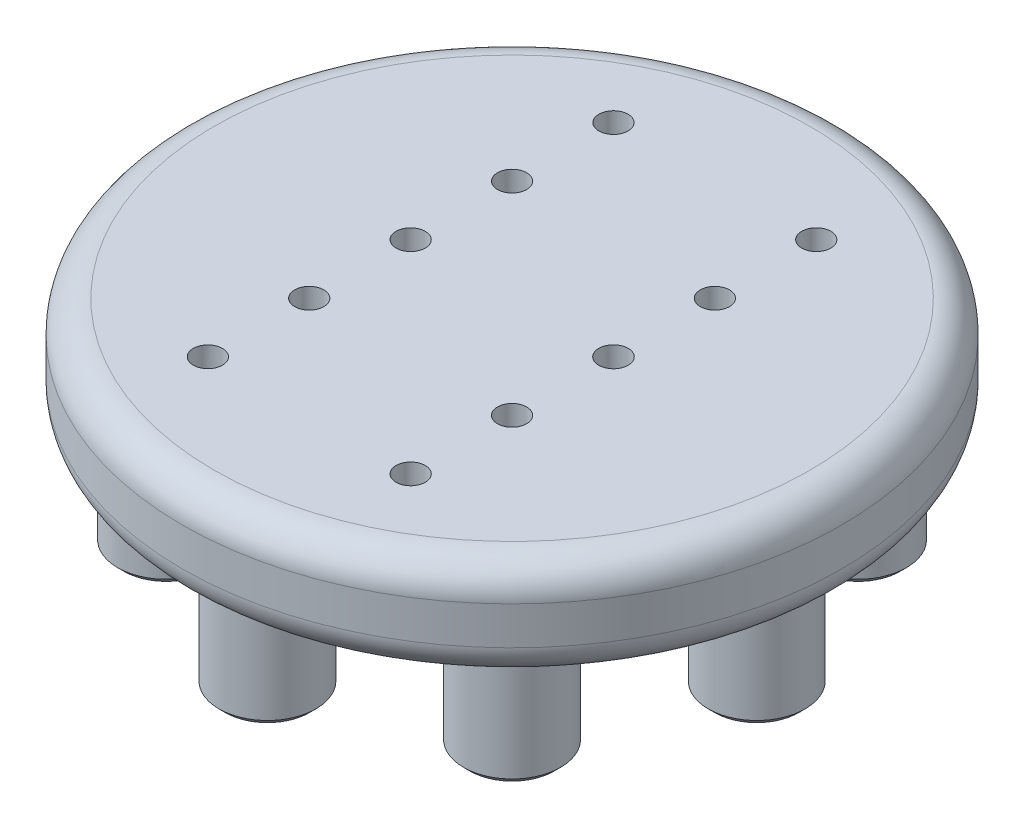
from build123d import *

# Parameters (mm, degrees)
SKETCH1_R           = 26
BOSS_EXTRUDE1_DEPTH = 8
SKETCH2_R           = 6.1
CUT_EXTRUDE2_DEPTH  = 3
SKETCH1_11_R        = 3.82
BOSS_EXTRUDE3_DEPTH = 9
FILLET1_R           = 2.5
SKETCH3_R           = 1.15
SKETCH3_R_2         = 1.160199873
CUT_EXTRUDE3_DEPTH  = 6
CHAMFER1_SIZE       = 0.5


with BuildPart() as part:
    # Sketch1 → Boss-Extrude1 (new body)
    with BuildSketch(Plane(origin=(0, 0, 0), x_dir=(1, 0, 0), z_dir=(0, 1, 0))):
        Circle(SKETCH1_R)
    extrude(amount=BOSS_EXTRUDE1_DEPTH)

    # Sketch2 → Cut-Extrude2 (cut)
    with BuildSketch(Plane.XZ):
        Circle(SKETCH2_R)
    extrude(amount=-CUT_EXTRUDE2_DEPTH, mode=Mode.SUBTRACT)

    # Sketch1_11 → Boss-Extrude3 (add)
    with BuildSketch(Plane(origin=(0, 0, 0), x_dir=(1, 0, 0), z_dir=(0, 1, 0))):
        with Locations((-13.647160877, 13.647160877)):
            Circle(SKETCH1_11_R)
        with Locations((0, 19.3)):
            Circle(SKETCH1_11_R)
        with Locations((13.647160877, 13.647160877)):
            Circle(SKETCH1_11_R)
        with Locations((19.3, 0)):
            Circle(SKETCH1_11_R)
        with Locations((13.647160877, -13.647160877)):
            Circle(SKETCH1_11_R)
        with Locations((0, -19.3)):
            Circle(SKETCH1_11_R)
        with Locations((-13.647160877, -13.647160877)):
            Circle(SKETCH1_11_R)
        with Locations((-19.3, 0)):
            Circle(SKETCH1_11_R)
    extrude(amount=-BOSS_EXTRUDE3_DEPTH)

    # Fillet1
    fillet1_edges = [part.edges().sort_by_distance(p)[0] for p in [
        (-26, 0, 0),
        (-26, 8, 0),
    ]]
    fillet(fillet1_edges, radius=FILLET1_R)

    # Sketch3 → Cut-Extrude3 (cut)
    with BuildSketch(Plane(origin=(0, 8, 0), x_dir=(1, 0, 0), z_dir=(0, 1, 0))):
        with Locations((-8, 16)):
            Circle(SKETCH3_R)
        with Locations((8, 16)):
            Circle(SKETCH3_R)
        with Locations((-8, 8)):
            Circle(SKETCH3_R)
        with Locations((8, 8)):
            Circle(SKETCH3_R)
        with Locations((-8, -8)):
            Circle(SKETCH3_R)
        with Locations((8, -8)):
            Circle(SKETCH3_R)
        with Locations((-8, -16)):
            Circle(SKETCH3_R)
        with Locations((8, -16)):
            Circle(SKETCH3_R)
        with Locations((-8, 0)):
            Circle(SKETCH3_R)
        with Locations((8, 0)):
            Circle(SKETCH3_R_2)
    extrude(amount=-CUT_EXTRUDE3_DEPTH, mode=Mode.SUBTRACT)

    # Chamfer1
    chamfer1_edges = [part.edges().sort_by_distance(p)[0] for p in [
        (-3.82, -9, 19.3),
        (9.827160877, -9, 13.647160877),
        (-17.467160877, -9, 13.647160877),
        (-23.12, -9, 0),
        (-17.467160877, -9, -13.647160877),
        (-3.82, -9, -19.3),
        (9.827160877, -9, -13.647160877),
        (15.48, -9, 0),
    ]]
    chamfer(chamfer1_edges, length=CHAMFER1_SIZE)


solid = part.part
